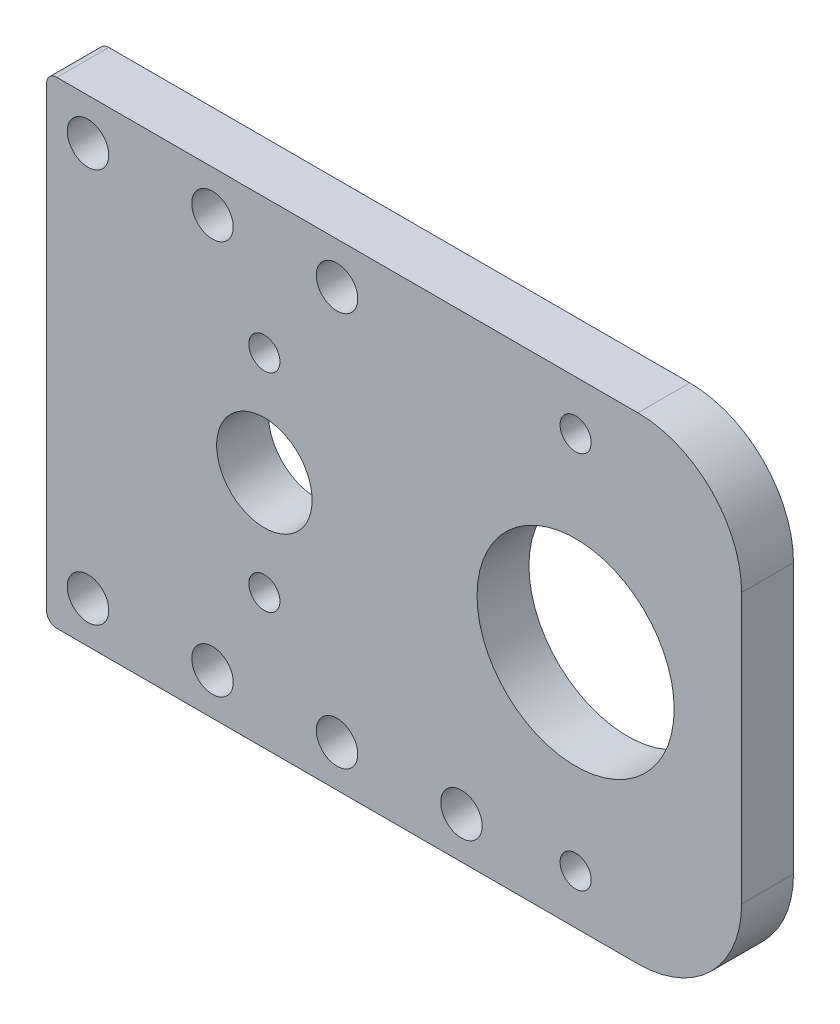
from build123d import *

# Parameters (mm, degrees)
SKETCH1_W           = 65
SKETCH1_H           = 46
SKETCH1_R           = 1.5
BOSS_EXTRUDE1_DEPTH = 5
SKETCH2_R           = 2
CUT_EXTRUDE1_DEPTH  = 10
SKETCH3_W           = 4
SKETCH3_H           = 46
CUT_EXTRUDE2_DEPTH  = 6
SKETCH4_W           = 6
SKETCH4_H           = 46
BOSS_EXTRUDE2_DEPTH = 5
FILLET1_R           = 10
FILLET2_R           = 1
SKETCH2_3_R         = 2
CUT_EXTRUDE3_DEPTH  = 10


with BuildPart() as part:
    # Sketch1 → Boss-Extrude1 (new body)
    with BuildSketch(Plane.XY):
        with Locations((7.5, 0)):
            Rectangle(SKETCH1_W, SKETCH1_H)
        with BuildLine():
            ThreePointArc((4.6, 0), (3.252691193, -3.252691193), (0, -4.6))
            ThreePointArc((0, -4.6), (-3.252691193, 3.252691193), (4.6, 0))
        make_face(mode=Mode.SUBTRACT)
        with Locations((30, -18.25)):
            Circle(SKETCH1_R, mode=Mode.SUBTRACT)
        with BuildLine():
            ThreePointArc((1.5, -10), (-1.060660172, -11.060660172), (0, -8.5))
            ThreePointArc((0, -8.5), (1.060660172, -8.939339828), (1.5, -10))
        make_face(mode=Mode.SUBTRACT)
        with BuildLine():
            ThreePointArc((39.5, 0), (23.282485579, -6.717514421), (30, 9.5))
            ThreePointArc((30, 9.5), (36.717514421, 6.717514421), (39.5, 0))
        make_face(mode=Mode.SUBTRACT)
        with Locations((0, 10)):
            Circle(SKETCH1_R, mode=Mode.SUBTRACT)
        with BuildLine():
            ThreePointArc((31.5, 18.25), (31.060660172, 17.189339828), (30, 16.75))
            ThreePointArc((30, 16.75), (28.939339828, 19.310660172), (31.5, 18.25))
        make_face(mode=Mode.SUBTRACT)
    extrude(amount=BOSS_EXTRUDE1_DEPTH)

    # Sketch2 → Cut-Extrude1 (cut)
    with BuildSketch(Plane.XY.offset(5)):
        with Locations((7, 19)):
            Circle(SKETCH2_R)
        with Locations((-5, -19)):
            Circle(SKETCH2_R)
        with Locations((-17, 19)):
            Circle(SKETCH2_R)
        with Locations((-5, 19)):
            Circle(SKETCH2_R)
        with Locations((7, -19)):
            Circle(SKETCH2_R)
        with Locations((-17, -19)):
            Circle(SKETCH2_R)
    extrude(amount=-CUT_EXTRUDE1_DEPTH, mode=Mode.SUBTRACT)

    # Sketch3 → Cut-Extrude2 (cut, through all)
    with BuildSketch(Plane.XY.offset(5)):
        with Locations((-23, 0)):
            Rectangle(SKETCH3_W, SKETCH3_H)
    extrude(amount=-CUT_EXTRUDE2_DEPTH, mode=Mode.SUBTRACT)

    # Sketch4 → Boss-Extrude2 (add)
    with BuildSketch(Plane.XY.offset(5)):
        with Locations((43, 0)):
            Rectangle(SKETCH4_W, SKETCH4_H)
    extrude(amount=-BOSS_EXTRUDE2_DEPTH)

    # Fillet1
    fillet1_edges = [part.edges().sort_by_distance(p)[0] for p in [
        (46, -23, 2.5),
        (46, 23, 2.5),
    ]]
    fillet(fillet1_edges, radius=FILLET1_R)

    # Fillet2
    fillet2_edges = [part.edges().sort_by_distance(p)[0] for p in [
        (-21, 23, 2.5),
        (-21, -23, 2.5),
    ]]
    fillet(fillet2_edges, radius=FILLET2_R)

    # Sketch2_3 → Cut-Extrude3 (cut)
    with BuildSketch(Plane.XY.offset(5)):
        with Locations((19, -19)):
            Circle(SKETCH2_3_R)
    extrude(amount=-CUT_EXTRUDE3_DEPTH, mode=Mode.SUBTRACT)


solid = part.part
